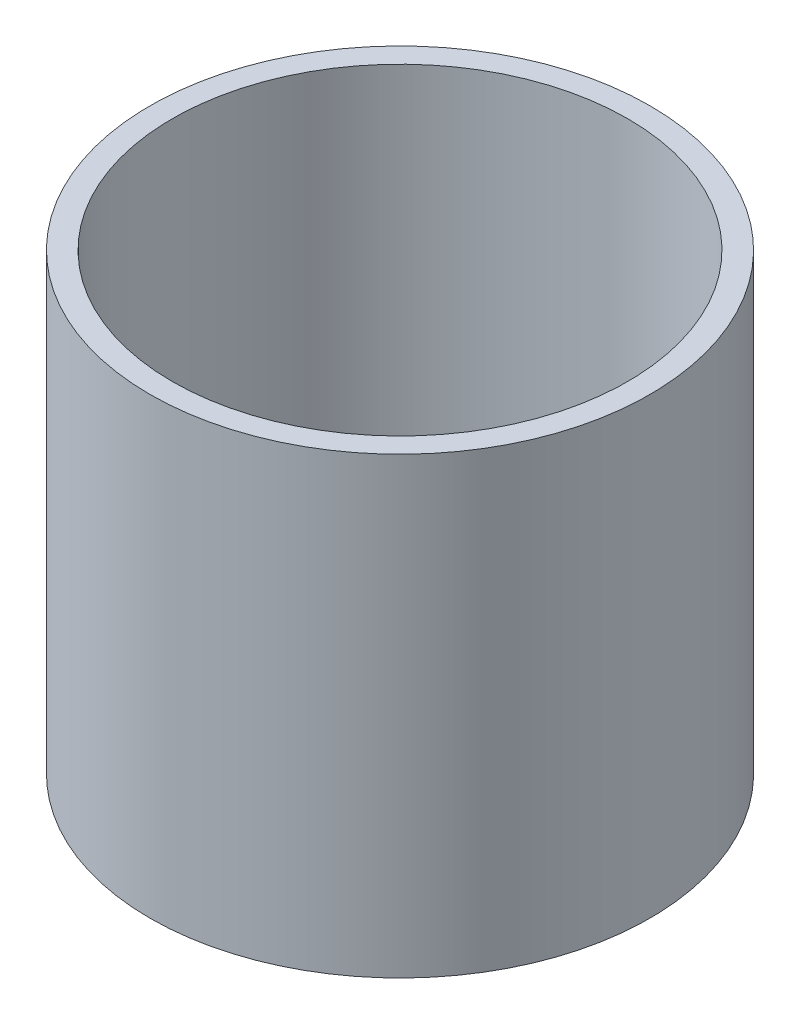
from build123d import *

# Parameters (mm, degrees)
SKETCH_1_W = 2.5
SKETCH_1_H = 50.8


with BuildPart() as part:
    # 草图1 → 旋转1 (revolve)
    with BuildSketch(Plane.XY, mode=Mode.PRIVATE) as revolve_1_sk:
        with Locations((26.75, 25.4)):
            Rectangle(SKETCH_1_W, SKETCH_1_H)
    revolve(revolve_1_sk.sketch.rotate(Axis((0, 161.376166943, 0), (0, -1, 0)), 90), axis=Axis((0, 161.376166943, 0), (0, -1, 0)))  # turned: the seam where the file's is


solid = part.part
